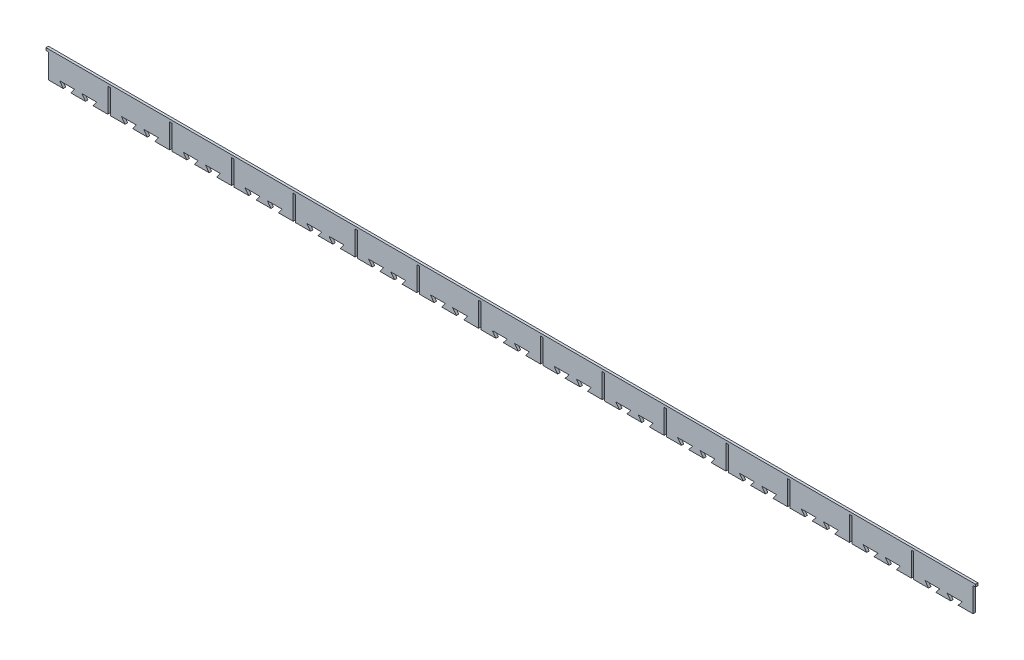
from build123d import *

# Parameters (mm, degrees)
BOSS_EXTRUDE1_DEPTH = 4


with BuildPart() as part:
    # Sketch2 → Boss-Extrude1 (new body)
    with BuildSketch(Plane.XY):
        Polygon((-778.491602678, 45.210025961), (-778.491602678, 41.210025961), (-774.491602678, 41.210025961), (-774.491602678, 1.805025961), (-750.491602678, 1.805025961), (-756.491602678, 9.805025961), (-732.491602678, 9.805025961), (-738.491602678, 1.805025961), (-714.491602678, 1.805025961), (-720.491602678, 9.805025961), (-696.491602678, 9.805025961), (-702.491602678, 1.805025961), (-678.491602678, 1.805025961), (-678.491602678, 41.210025961), (-674.491602678, 41.210025961), (-674.491602678, 1.805025961), (-650.491602678, 1.805025961), (-656.491602678, 9.805025961), (-632.491602678, 9.805025961), (-638.491602678, 1.805025961), (-614.491602678, 1.805025961), (-620.491602678, 9.805025961), (-596.491602678, 9.805025961), (-602.491602678, 1.805025961), (-578.491602678, 1.805025961), (-578.491602678, 41.210025961), (-574.491602678, 41.210025961), (-574.491602678, 1.805025961), (-550.491602678, 1.805025961), (-556.491602678, 9.805025961), (-532.491602678, 9.805025961), (-538.491602678, 1.805025961), (-514.491602678, 1.805025961), (-520.491602678, 9.805025961), (-496.491602678, 9.805025961), (-502.491602678, 1.805025961), (-478.491602678, 1.805025961), (-478.491602678, 41.210025961), (-474.491602678, 41.210025961), (-474.491602678, 1.805025961), (-450.491602678, 1.805025961), (-456.491602678, 9.805025961), (-432.491602678, 9.805025961), (-438.491602678, 1.805025961), (-414.491602678, 1.805025961), (-420.491602678, 9.805025961), (-396.491602678, 9.805025961), (-402.491602678, 1.805025961), (-378.491602678, 1.805025961), (-378.491602678, 41.210025961), (-374.491602678, 41.210025961), (-374.491602678, 1.805025961), (-350.491602678, 1.805025961), (-356.491602678, 9.805025961), (-332.491602678, 9.805025961), (-338.491602678, 1.805025961), (-314.491602678, 1.805025961), (-320.491602678, 9.805025961), (-296.491602678, 9.805025961), (-302.491602678, 1.805025961), (-278.491602678, 1.805025961), (-278.491602678, 41.210025961), (-274.491602678, 41.210025961), (-274.491602678, 1.805025961), (-250.491602678, 1.805025961), (-256.491602678, 9.805025961), (-232.491602678, 9.805025961), (-238.491602678, 1.805025961), (-214.491602678, 1.805025961), (-220.491602678, 9.805025961), (-196.491602678, 9.805025961), (-202.491602678, 1.805025961), (-178.491602678, 1.805025961), (-178.491602678, 41.210025961), (-174.491602678, 41.210025961), (-174.491602678, 1.805025961), (-150.491602678, 1.805025961), (-156.491602678, 9.805025961), (-132.491602678, 9.805025961), (-138.491602678, 1.805025961), (-114.491602678, 1.805025961), (-120.491602678, 9.805025961), (-96.491602678, 9.805025961), (-102.491602678, 1.805025961), (-78.491602678, 1.805025961), (-78.491602678, 41.210025961), (-74.491602678, 41.210025961), (-74.491602678, 1.805025961), (-50.491602678, 1.805025961), (-56.491602678, 9.805025961), (-32.491602678, 9.805025961), (-38.491602678, 1.805025961), (-14.491602678, 1.805025961), (-20.491602678, 9.805025961), (3.508397322, 9.805025961), (-2.491602678, 1.805025961), (21.508397322, 1.805025961), (21.508397322, 41.210025961), (25.508397322, 41.210025961), (25.508397322, 1.805025961), (49.508397322, 1.805025961), (43.508397322, 9.805025961), (67.508397322, 9.805025961), (61.508397322, 1.805025961), (85.508397322, 1.805025961), (79.508397322, 9.805025961), (103.508397322, 9.805025961), (97.508397322, 1.805025961), (121.508397322, 1.805025961), (121.508397322, 41.210025961), (125.508397322, 41.210025961), (125.508397322, 1.805025961), (149.508397322, 1.805025961), (143.508397322, 9.805025961), (167.508397322, 9.805025961), (161.508397322, 1.805025961), (185.508397322, 1.805025961), (179.508397322, 9.805025961), (203.508397322, 9.805025961), (197.508397322, 1.805025961), (221.508397322, 1.805025961), (221.508397322, 41.210025961), (225.508397322, 41.210025961), (225.508397322, 1.805025961), (249.508397322, 1.805025961), (243.508397322, 9.805025961), (267.508397322, 9.805025961), (261.508397322, 1.805025961), (285.508397322, 1.805025961), (279.508397322, 9.805025961), (303.508397322, 9.805025961), (297.508397322, 1.805025961), (321.508397322, 1.805025961), (321.508397322, 41.210025961), (325.508397322, 41.210025961), (325.508397322, 1.805025961), (349.508397322, 1.805025961), (343.508397322, 9.805025961), (367.508397322, 9.805025961), (361.508397322, 1.805025961), (385.508397322, 1.805025961), (379.508397322, 9.805025961), (403.508397322, 9.805025961), (397.508397322, 1.805025961), (421.508397322, 1.805025961), (421.508397322, 41.210025961), (425.508397322, 41.210025961), (425.508397322, 1.805025961), (449.508397322, 1.805025961), (443.508397322, 9.805025961), (467.508397322, 9.805025961), (461.508397322, 1.805025961), (485.508397322, 1.805025961), (479.508397322, 9.805025961), (503.508397322, 9.805025961), (497.508397322, 1.805025961), (521.508397322, 1.805025961), (521.508397322, 41.210025961), (525.508397322, 41.210025961), (525.508397322, 1.805025961), (549.508397322, 1.805025961), (543.508397322, 9.805025961), (567.508397322, 9.805025961), (561.508397322, 1.805025961), (585.508397322, 1.805025961), (579.508397322, 9.805025961), (603.508397322, 9.805025961), (597.508397322, 1.805025961), (621.508397322, 1.805025961), (621.508397322, 41.210025961), (625.508397322, 41.210025961), (625.508397322, 1.805025961), (649.508397322, 1.805025961), (643.508397322, 9.805025961), (667.508397322, 9.805025961), (661.508397322, 1.805025961), (685.508397322, 1.805025961), (679.508397322, 9.805025961), (703.508397322, 9.805025961), (697.508397322, 1.805025961), (721.508397322, 1.805025961), (721.508397322, 41.210025961), (725.508397322, 41.210025961), (725.508397322, 45.210025961), align=None)
    extrude(amount=BOSS_EXTRUDE1_DEPTH)


solid = part.part
